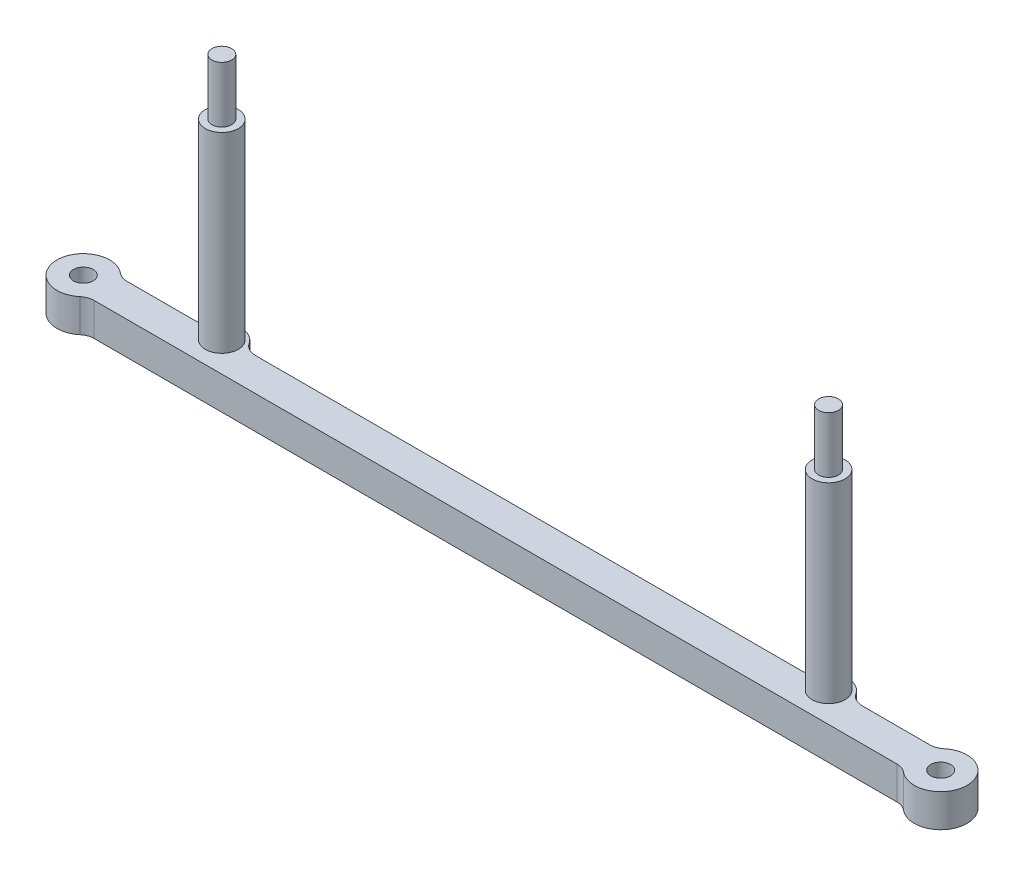
from build123d import *

# Parameters (mm, degrees)
SKETCH1_R           = 1.5
BOSS_EXTRUDE1_DEPTH = 5
FILLET1_R           = 2.5
SKETCH2_R           = 2.5
BOSS_EXTRUDE2_DEPTH = 29
SKETCH3_R           = 1.5
BOSS_EXTRUDE3_DEPTH = 8.5


with BuildPart() as part:
    # Sketch1 → Boss-Extrude1 (new body)
    with BuildSketch(Plane(origin=(0, 0, 0), x_dir=(1, 0, 0), z_dir=(0, 1, 0))):
        with BuildLine():
            Line((-48.958039892, 2.5), (-61.877501001, 2.5))
            ThreePointArc((-61.877501001, 2.5), (-69, 0), (-61.877501001, -2.5))
            Line((-61.877501001, -2.5), (61.877501001, -2.5))
            ThreePointArc((61.877501001, -2.5), (69, 0), (61.877501001, 2.5))
            Line((61.877501001, 2.5), (48.958039892, 2.5))
            ThreePointArc((48.958039892, 2.5), (46, 5), (43.041960108, 2.5))
            Line((43.041960108, 2.5), (-43.041960108, 2.5))
            ThreePointArc((-43.041960108, 2.5), (-46, 5), (-48.958039892, 2.5))
        make_face()
        with Locations((-65, 0)):
            Circle(SKETCH1_R, mode=Mode.SUBTRACT)
        with Locations((65, 0)):
            Circle(SKETCH1_R, mode=Mode.SUBTRACT)
    extrude(amount=BOSS_EXTRUDE1_DEPTH)

    # Fillet1
    fillet1_edges = [part.edges().sort_by_distance(p)[0] for p in [
        (61.877501001, 2.5, -2.5),
        (61.877501001, 2.5, 2.5),
        (-61.877501001, 2.5, 2.5),
        (-61.877501001, 2.5, -2.5),
        (-48.958039892, 2.5, -2.5),
        (-43.041960108, 2.5, -2.5),
        (43.041960108, 2.5, -2.5),
        (48.958039892, 2.5, -2.5),
    ]]
    fillet(fillet1_edges, radius=FILLET1_R)

    # Sketch2 → Boss-Extrude2 (add)
    with BuildSketch(Plane(origin=(0, 5, 0), x_dir=(1, 0, 0), z_dir=(0, 1, 0))):
        with Locations((-46, 2)):
            Circle(SKETCH2_R)
        with Locations((46, 2)):
            Circle(SKETCH2_R)
    extrude(amount=BOSS_EXTRUDE2_DEPTH)

    # Sketch3 → Boss-Extrude3 (add)
    with BuildSketch(Plane(origin=(0, 34, 0), x_dir=(1, 0, 0), z_dir=(0, 1, 0))):
        with Locations((-46, 2)):
            Circle(SKETCH3_R)
        with Locations((46, 2)):
            Circle(SKETCH3_R)
    extrude(amount=BOSS_EXTRUDE3_DEPTH)


solid = part.part
